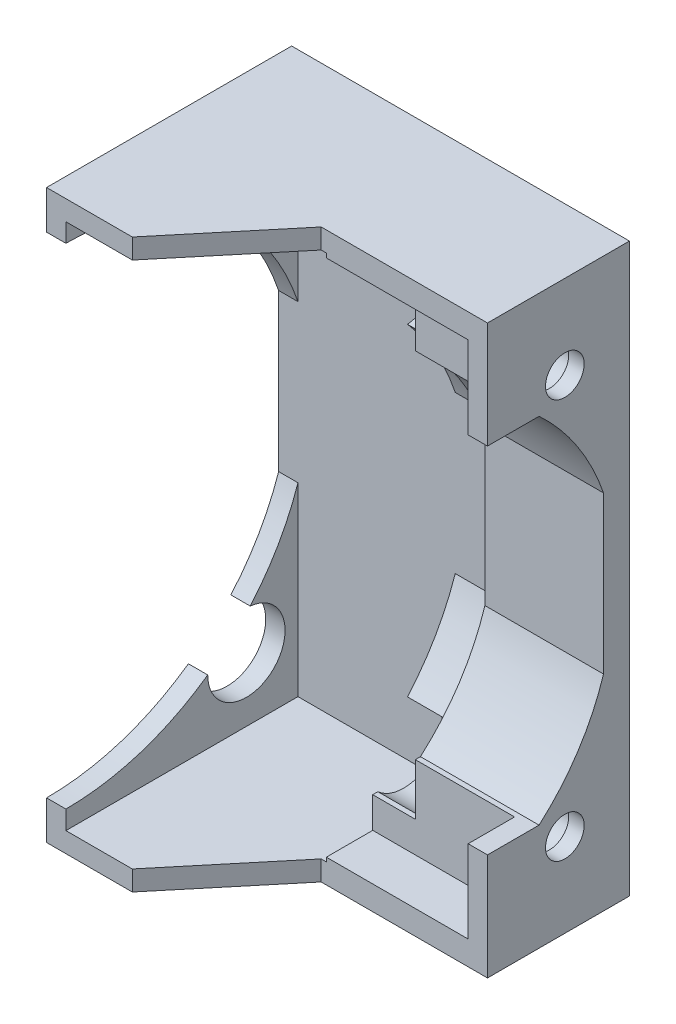
from build123d import *

# Parameters (mm, degrees)
CROQUIS1_W               = 25
CROQUIS1_H               = 44
SALIENTE_EXTRUIR1_DEPTH  = 20
CROQUIS2_W               = 11.3
CROQUIS2_H               = 40.4
CORTAR_EXTRUIR1_DEPTH    = 18
CROQUIS3_W               = 10.7
CROQUIS3_H               = 44
CORTAR_EXTRUIR2_DEPTH    = 12
CORTAR_EXTRUIR3_START    = -25
CROQUIS4_R               = 1.6
CORTAR_EXTRUIR3_DEPTH    = 25
CROQUIS5_R               = 3
CORTAR_EXTRUIR4_DEPTH    = 17
CROQUIS7_W               = 10.7
CROQUIS7_H               = 2.131966011
SALIENTE_EXTRUIR2_DEPTH  = 12
CROQUIS9_W               = 11.3
CROQUIS9_H               = 12.16552506
SALIENTE_EXTRUIR3_DEPTH  = 2
SALIENTE_EXTRUIR4_DEPTH  = 2
CORTAR_EXTRUIR10_START   = -25
CROQUIS12_W              = 0.99
CROQUIS12_H              = 44
CORTAR_EXTRUIR10_DEPTH   = 25
CROQUIS13_W              = 8
CROQUIS13_H              = 44
CORTAR_EXTRUIR11_DEPTH   = 11.7
SALIENTE_EXTRUIR5_DEPTH  = 11.7
CROQUIS15_W              = 10.763613753
CROQUIS15_H              = 40.736067978
CORTAR_EXTRUIR12_DEPTH   = 4
CROQUIS16_R              = 1.5
SALIENTE_EXTRUIR6_DEPTH  = 1.2
CORTAR_EXTRUIR13_START   = -44
CORTAR_EXTRUIR13_DEPTH   = 44
CROQUIS18_W              = 0.936386247
CROQUIS18_H              = 40.568033989
CORTAR_EXTRUIR14_DEPTH   = 4
SALIENTE_EXTRUIR7_START  = -9.2
SALIENTE_EXTRUIR7_DEPTH  = 9.2
SALIENTE_EXTRUIR8_START  = -12.9
CROQUIS20_W              = 4
CROQUIS20_H              = 0.236067978
CROQUIS20_H_2            = 0.25
SALIENTE_EXTRUIR8_DEPTH  = 12.9
CROQUIS21_W              = 4
CROQUIS21_H              = 6.401046148
CROQUIS21_H_2            = 6.387114126
SALIENTE_EXTRUIR9_DEPTH  = 1.5
SALIENTE_EXTRUIR10_DEPTH = 0.4
CORTAR_EXTRUIR15_START   = -18
CROQUIS23_W              = 12.2
CROQUIS23_H              = 40.9
CORTAR_EXTRUIR15_DEPTH   = 18


with BuildPart() as part:
    # Croquis1 → Saliente-Extruir1 (new body)
    with BuildSketch(Plane.XY):
        with Locations((-22.114132301, -13.090425532)):
            Rectangle(CROQUIS1_W, CROQUIS1_H)
    extrude(amount=SALIENTE_EXTRUIR1_DEPTH)

    # Croquis2 → Cortar-Extruir1 (cut)
    with BuildSketch(Plane.XY.offset(20)):
        with Locations((-26.964132301, -13.090425532)):
            Rectangle(CROQUIS2_W, CROQUIS2_H)
    extrude(amount=-CORTAR_EXTRUIR1_DEPTH, mode=Mode.SUBTRACT)

    # Croquis3 → Cortar-Extruir2 (cut)
    with BuildSketch(Plane.XY.offset(20)):
        with Locations((-14.964132301, -13.090425532)):
            Rectangle(CROQUIS3_W, CROQUIS3_H)
    extrude(amount=-CORTAR_EXTRUIR2_DEPTH, mode=Mode.SUBTRACT)

    # Croquis4 → Cortar-Extruir3 (cut)
    with BuildSketch(Plane.ZY.offset(34.614132301).offset(CORTAR_EXTRUIR3_START)):
        with Locations((6, 2.409574468)):
            Circle(CROQUIS4_R)
        with Locations((6, -28.590425532)):
            Circle(CROQUIS4_R)
        with BuildLine():
            Line((20, 5.909574468), (20, -32.090425532))
            ThreePointArc((20, -32.090425532), (1, -13.090425532), (20, 5.909574468))
        make_face()
    extrude(amount=CORTAR_EXTRUIR3_DEPTH, mode=Mode.SUBTRACT)

    # Croquis5 → Cortar-Extruir4 (cut)
    with BuildSketch(Plane.ZY.offset(34.614132301)):
        with Locations((6, 2.409574468)):
            Circle(CROQUIS5_R)
        with Locations((6, -28.590425532)):
            Circle(CROQUIS5_R)
    extrude(amount=-CORTAR_EXTRUIR4_DEPTH, mode=Mode.SUBTRACT)

    # Croquis7 → Saliente-Extruir2 (add)
    with BuildSketch(Plane.XY.offset(8)):
        with Locations((-14.964132301, -34.024442527)):
            Rectangle(CROQUIS7_W, CROQUIS7_H)
        with Locations((-14.964132301, 7.843591463)):
            Rectangle(CROQUIS7_W, CROQUIS7_H)
    extrude(amount=SALIENTE_EXTRUIR2_DEPTH)

    # Croquis9 → Saliente-Extruir3 (add)
    with BuildSketch(Plane.XY.offset(2)):
        with Locations((-26.964132301, -13.090425532)):
            Rectangle(CROQUIS9_W, CROQUIS9_H)
    extrude(amount=-SALIENTE_EXTRUIR3_DEPTH)

    # Croquis11 → Saliente-Extruir4 (add)
    with BuildSketch(Plane.ZY.offset(32.614132301)):
        with BuildLine():
            Line((2, -7.007663002), (2, -19.173188062))
            ThreePointArc((2, -19.173188062), (1, -13.090425532), (2, -7.007663002))
        make_face()
    extrude(amount=SALIENTE_EXTRUIR4_DEPTH)

    # Croquis12 → Cortar-Extruir10 (cut)
    with BuildSketch(Plane.ZY.offset(34.614132301).offset(CORTAR_EXTRUIR10_START)):
        with Locations((0.495, -13.090425532)):
            Rectangle(CROQUIS12_W, CROQUIS12_H)
    extrude(amount=CORTAR_EXTRUIR10_DEPTH, mode=Mode.SUBTRACT)

    # Croquis13 → Cortar-Extruir11 (cut)
    with BuildSketch(Plane(origin=(-9.614132301, 0, 0), x_dir=(0, 0, -1), z_dir=(1, 0, 0))):
        with Locations((-16, -13.090425532)):
            Rectangle(CROQUIS13_W, CROQUIS13_H)
    extrude(amount=-CORTAR_EXTRUIR11_DEPTH, mode=Mode.SUBTRACT)

    # Croquis14 → Saliente-Extruir5 (add)
    with BuildSketch(Plane(origin=(-21.314132301, 0, 0), x_dir=(0, 0, -1), z_dir=(1, 0, 0))):
        with BuildLine():
            Line((-2, -19.173188062), (-2, -7.007663002))
            ThreePointArc((-2, -7.007663002), (-1, -13.090425532), (-2, -19.173188062))
        make_face()
    extrude(amount=SALIENTE_EXTRUIR5_DEPTH)

    # Croquis15 → Cortar-Extruir12 (cut)
    with BuildSketch(Plane.XY.offset(12)):
        with Locations((-14.995939178, -13.090425532)):
            Rectangle(CROQUIS15_W, CROQUIS15_H)
    extrude(amount=-CORTAR_EXTRUIR12_DEPTH, mode=Mode.SUBTRACT)

    # Croquis16 → Saliente-Extruir6 (add)
    with BuildSketch(Plane(origin=(-9.614132301, 0, 0), x_dir=(0, 0, -1), z_dir=(1, 0, 0))):
        with BuildLine():
            Line((-8, -27.821345395), (-8, -33.458459521))
            Line((-8, -33.458459521), (-12, -33.458459521))
            Line((-12, -33.458459521), (-12, -35.090425532))
            Line((-12, -35.090425532), (-0.99, -35.090425532))
            Line((-0.99, -35.090425532), (-0.99, 8.909574468))
            Line((-0.99, 8.909574468), (-12, 8.909574468))
            Line((-12, 8.909574468), (-12, 7.277608457))
            Line((-12, 7.277608457), (-8, 7.277608457))
            Line((-8, 7.277608457), (-8, 1.640494331))
            ThreePointArc((-8, 1.640494331), (-4.389181434, -2.259804881), (-2, -7.007663002))
            Line((-2, -7.007663002), (-2, -19.173188062))
            ThreePointArc((-2, -19.173188062), (-4.389181434, -23.921046183), (-8, -27.821345395))
        make_face()
        with Locations((-6, -28.590425532)):
            Circle(CROQUIS16_R, mode=Mode.SUBTRACT)
        with Locations((-6, 2.409574468)):
            Circle(CROQUIS16_R, mode=Mode.SUBTRACT)
    extrude(amount=SALIENTE_EXTRUIR6_DEPTH)

    # Croquis17 → Cortar-Extruir13 (cut)
    with BuildSketch(Plane.XZ.offset(35.090425532).offset(CORTAR_EXTRUIR13_START)):
        Polygon((-21.314132301, 12), (-21.314132301, 20), (-27.964132301, 20), align=None)
    extrude(amount=CORTAR_EXTRUIR13_DEPTH, mode=Mode.SUBTRACT)

    # Croquis18 → Cortar-Extruir14 (cut)
    with BuildSketch(Plane.XY.offset(12)):
        with Locations((-20.845939178, -13.006408538)):
            Rectangle(CROQUIS18_W, CROQUIS18_H)
    extrude(amount=-CORTAR_EXTRUIR14_DEPTH, mode=Mode.SUBTRACT)

    # Croquis19 → Saliente-Extruir7 (add)
    with BuildSketch(Plane(origin=(-8.414132301, 0, 0), x_dir=(0, 0, -1), z_dir=(1, 0, 0)).offset(SALIENTE_EXTRUIR7_START)):
        with BuildLine():
            Line((-2, -19.173188062), (-2, -7.007663002))
            ThreePointArc((-2, -7.007663002), (-4.389181434, -2.259804881), (-8, 1.640494331))
            Line((-8, 1.640494331), (-8, 0.640494331))
            ThreePointArc((-8, 0.640494331), (-5.026875227, -2.874277954), (-3, -7.007663002))
            Line((-3, -7.007663002), (-3, -19.173188062))
            ThreePointArc((-3, -19.173188062), (-4.972698099, -23.341991528), (-8, -26.821345395))
            Line((-8, -26.821345395), (-8, -27.821345395))
            ThreePointArc((-8, -27.821345395), (-4.389181434, -23.921046183), (-2, -19.173188062))
        make_face()
    extrude(amount=SALIENTE_EXTRUIR7_DEPTH)

    # Croquis20 → Saliente-Extruir8 (add)
    with BuildSketch(Plane(origin=(-8.414132301, 0, 0), x_dir=(0, 0, -1), z_dir=(1, 0, 0)).offset(SALIENTE_EXTRUIR8_START)):
        with Locations((-10, -33.340425532)):
            Rectangle(CROQUIS20_W, CROQUIS20_H)
        with Locations((-10, 7.152608457)):
            Rectangle(CROQUIS20_W, CROQUIS20_H_2)
    extrude(amount=SALIENTE_EXTRUIR8_DEPTH)

    # Croquis21 → Saliente-Extruir9 (add)
    with BuildSketch(Plane(origin=(-8.414132301, 0, 0), x_dir=(0, 0, -1), z_dir=(1, 0, 0))):
        with Locations((-10, -30.021868469)):
            Rectangle(CROQUIS21_W, CROQUIS21_H)
        with Locations((-10, 3.834051394)):
            Rectangle(CROQUIS21_W, CROQUIS21_H_2)
    extrude(amount=-SALIENTE_EXTRUIR9_DEPTH)

    # Croquis22 → Saliente-Extruir10 (add)
    with BuildSketch(Plane.XY.offset(8)):
        Polygon((-9.914132301, 7.027608457), (-21.314132301, 7.027608457), (-21.314132301, 4.645642446), (-17.614132301, 4.645642446), (-17.614132301, 0.640494331), (-9.914132301, 0.640494331), align=None)
        Polygon((-9.914132301, -26.821345395), (-17.614132301, -26.821345395), (-17.614132301, -30.826493509), (-21.314132301, -30.826493509), (-21.314132301, -33.222391543), (-9.914132301, -33.222391543), align=None)
    extrude(amount=SALIENTE_EXTRUIR10_DEPTH)

    # Croquis23 → Cortar-Extruir15 (cut)
    with BuildSketch(Plane.XY.offset(20).offset(CORTAR_EXTRUIR15_START)):
        with Locations((-27.014132301, -13.090425532)):
            Rectangle(CROQUIS23_W, CROQUIS23_H)
    extrude(amount=CORTAR_EXTRUIR15_DEPTH, mode=Mode.SUBTRACT)


solid = part.part
